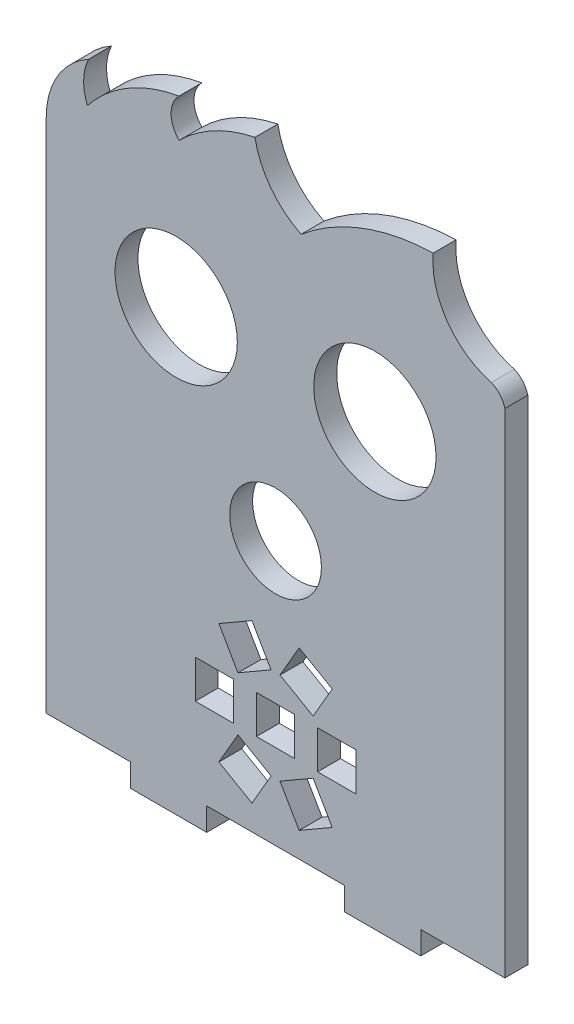
from build123d import *

# Parameters (mm, degrees)
MODEL_R                 = 8
MODEL_R_2               = 6
MODEL_W                 = 5
MODEL_H                 = 5
SALIENTE_EXTRUIR1_DEPTH = 3


with BuildPart() as part:
    # Model → Saliente-Extruir1 (new body)
    with BuildSketch(Plane.XY):
        with BuildLine():
            Line((61.213620508, -33.681899018), (61.213620508, -30.681899018))
            Line((61.213620508, -30.681899018), (72.213620508, -30.681899018))
            Line((72.213620508, -30.681899018), (72.213620508, 33.843176043))
            ThreePointArc((72.213620508, 33.843176043), (71.581524876, 35.086982401), (70.455188077, 35.910368434))
            ThreePointArc((70.455188077, 35.910368434), (64.669766101, 39.948265328), (62.836385617, 46.76107934))
            ThreePointArc((62.836385617, 46.76107934), (53.642761225, 44.976523513), (45.555825702, 40.25329974))
            ThreePointArc((45.555825702, 40.25329974), (41.596417991, 43.526874671), (39.519003289, 48.225550059))
            ThreePointArc((39.519003289, 48.225550059), (34.170956472, 46.290742797), (29.593449084, 42.915611688))
            ThreePointArc((29.593449084, 42.915611688), (28.54639925, 45.410810501), (29.570395214, 47.91555854))
            ThreePointArc((29.570395214, 47.91555854), (22.931595109, 45.498988779), (17.602798188, 40.860303661))
            ThreePointArc((17.602798188, 40.860303661), (17.108097579, 43.537370136), (17.749822475, 46.183046374))
            ThreePointArc((17.749822475, 46.183046374), (13.701405336, 42.272017764), (12.213620508, 36.843176043))
            Line((12.213620508, 36.843176043), (12.213620508, -30.681899018))
            Line((12.213620508, -30.681899018), (23.213620508, -30.681899018))
            Line((23.213620508, -30.681899018), (23.213620508, -33.681899018))
            Line((23.213620508, -33.681899018), (33.213620508, -33.681899018))
            Line((33.213620508, -33.681899018), (33.213620508, -30.681899018))
            Line((33.213620508, -30.681899018), (51.213620508, -30.681899018))
            Line((51.213620508, -30.681899018), (51.213620508, -33.681899018))
            Line((51.213620508, -33.681899018), (61.213620508, -33.681899018))
        make_face()
        with Locations((55.213620508, 23.843176043)):
            Circle(MODEL_R, mode=Mode.SUBTRACT)
        with Locations((29.213620508, 23.843176043)):
            Circle(MODEL_R, mode=Mode.SUBTRACT)
        with Locations((42.213620508, 3.843176043)):
            Circle(MODEL_R_2, mode=Mode.SUBTRACT)
        Polygon((47.128684017, -13.559678303), (49.628684017, -9.229551284), (45.298556998, -6.729551284), (42.798556998, -11.059678303), align=None, mode=Mode.SUBTRACT)
        Polygon((34.798556998, -9.229551284), (37.298556998, -13.559678303), (41.628684017, -11.059678303), (39.128684017, -6.729551284), align=None, mode=Mode.SUBTRACT)
        with Locations((50.213620508, -17.072818024)):
            Rectangle(MODEL_W, MODEL_H, mode=Mode.SUBTRACT)
        with Locations((42.213620508, -17.072818024)):
            Rectangle(MODEL_W, MODEL_H, mode=Mode.SUBTRACT)
        Polygon((49.628684017, -24.916084764), (47.128684017, -20.585957745), (42.798556998, -23.085957745), (45.298556998, -27.416084764), align=None, mode=Mode.SUBTRACT)
        with Locations((34.213620508, -17.072818024)):
            Rectangle(MODEL_W, MODEL_H, mode=Mode.SUBTRACT)
        Polygon((37.298556998, -20.585957745), (34.798556998, -24.916084764), (39.128684017, -27.416084764), (41.628684017, -23.085957745), align=None, mode=Mode.SUBTRACT)
    extrude(amount=SALIENTE_EXTRUIR1_DEPTH)


solid = part.part
